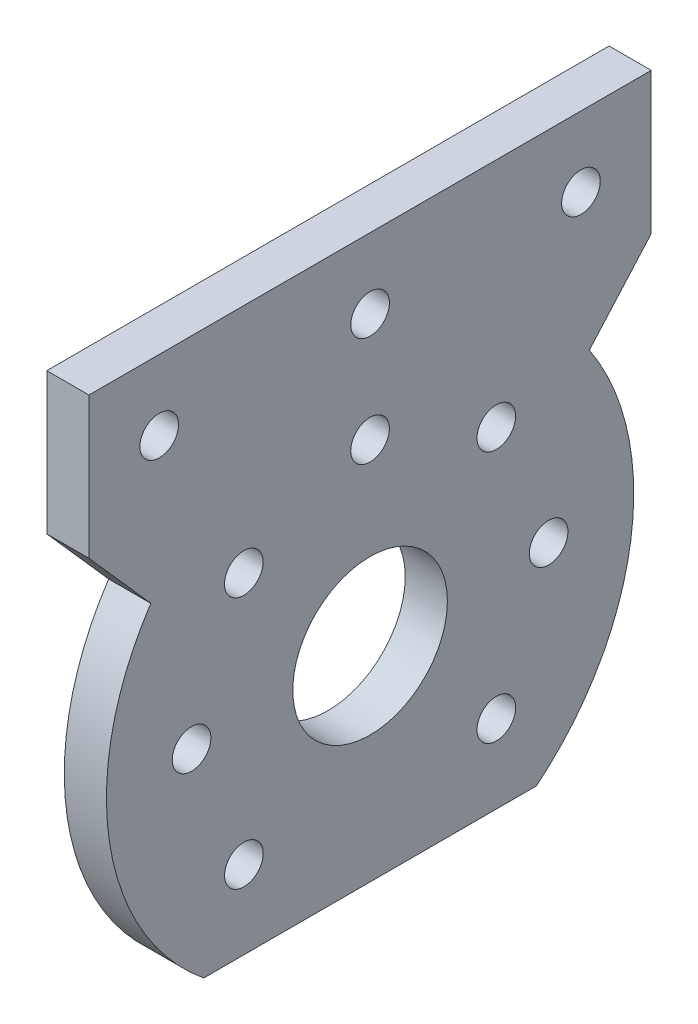
from build123d import *

# Parameters (mm, degrees)
SKETCH1_W           = 80
SKETCH1_H           = 80
BOSS_EXTRUDE1_DEPTH = 6
SKETCH2_R           = 11
SKETCH2_R_2         = 2.75
CUT_EXTRUDE1_DEPTH  = 7
SKETCH3_R           = 2.75
CUT_EXTRUDE2_DEPTH  = 7
CUT_EXTRUDE3_DEPTH  = 7


with BuildPart() as part:
    # Sketch1 → Boss-Extrude1 (new body)
    with BuildSketch(Plane(origin=(0, 0, 0), x_dir=(0, 0, -1), z_dir=(1, 0, 0))):
        with Locations((11.749387771, -15.012106538)):
            Rectangle(SKETCH1_W, SKETCH1_H)
    extrude(amount=BOSS_EXTRUDE1_DEPTH)

    # Sketch2 → Cut-Extrude1 (cut, through all)
    with BuildSketch(Plane(origin=(6, 0, 0), x_dir=(0, 0, -1), z_dir=(1, 0, 0))):
        with Locations((11.749387771, -25.911850923)):
            Circle(SKETCH2_R)
        with Locations((-18.250612229, 14.987893462)):
            Circle(SKETCH2_R_2)
        with Locations((41.749387771, 14.987893462)):
            Circle(SKETCH2_R_2)
        with Locations((11.749387771, 14.987893462)):
            Circle(SKETCH2_R_2)
    extrude(amount=-CUT_EXTRUDE1_DEPTH, mode=Mode.SUBTRACT)

    # Sketch3 → Cut-Extrude2 (cut, through all)
    with BuildSketch(Plane.ZY):
        with Locations((6.216594167, -7.956810044)):
            Circle(SKETCH3_R)
        with Locations((-11.741651274, -0.511852102)):
            Circle(SKETCH3_R)
        with Locations((-29.704428651, -7.945868985)):
            Circle(SKETCH3_R)
        with Locations((-37.149386593, -25.904114427)):
            Circle(SKETCH3_R)
        with Locations((-29.715369709, -43.866891803)):
            Circle(SKETCH3_R)
        with Locations((6.205653109, -43.877832862)):
            Circle(SKETCH3_R)
        with Locations((13.650611051, -25.91958742)):
            Circle(SKETCH3_R)
    extrude(amount=-CUT_EXTRUDE2_DEPTH, mode=Mode.SUBTRACT)

    # Sketch5 → Cut-Extrude3 (cut, through all)
    with BuildSketch(Plane(origin=(6, 0, 0), x_dir=(0, 0, -1), z_dir=(1, 0, 0))):
        with BuildLine():
            Line((-19.446404481, -5.087804094), (-28.250612229, 4.870195687))
            Line((-28.250612229, 4.870195687), (-37.780318954, -56.381008327))
            Line((-37.780318954, -56.381008327), (19.620213458, -79.7647401))
            Line((19.620213458, -79.7647401), (69.424766919, -54.649801307))
            Line((69.424766919, -54.649801307), (51.749387771, 4.870195687))
            Line((51.749387771, 4.870195687), (42.945180022, -5.087804094))
            ThreePointArc((42.945180022, -5.087804094), (11.749387771, -63.419428565), (-19.446404481, -5.087804094))
        make_face()
    extrude(amount=-CUT_EXTRUDE3_DEPTH, mode=Mode.SUBTRACT)


solid = part.part
